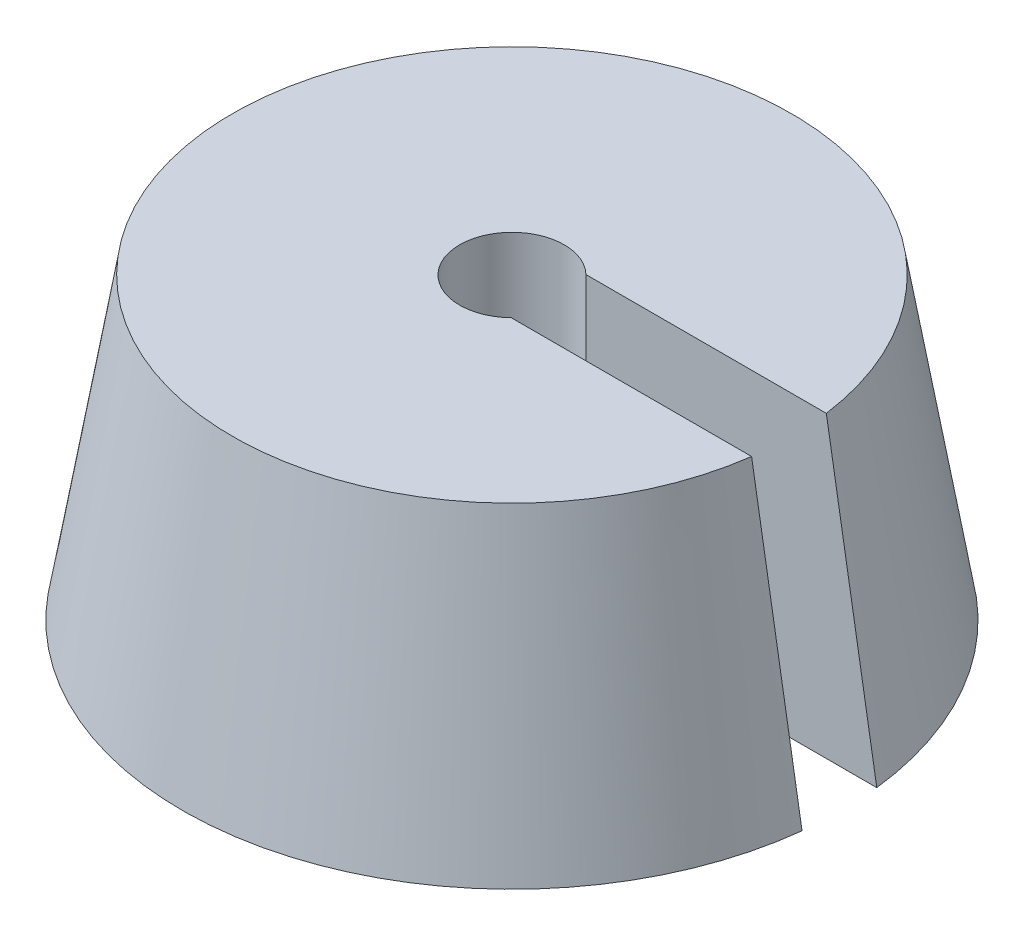
from build123d import *

# Parameters (mm, degrees)
SKETCH_1_R               = 22.05
SKETCH_2_R               = 18.7
CUT_EXTRUDE_2_DEPTH      = 1.0000001
CUT_EXTRUDE_2_DEPTH_BACK = 21.0000001


with BuildPart() as part:
    # 스케치1 → 로프트1 section 0
    with BuildSketch(Plane(origin=(0, 0, 0), x_dir=(1, 0, 0), z_dir=(0, 1, 0))):
        Circle(SKETCH_1_R)
    # 스케치2 → 로프트1 section 1
    with BuildSketch(Plane(origin=(0, 20, 0), x_dir=(1, 0, 0), z_dir=(0, 1, 0))):
        Circle(SKETCH_2_R)
    loft()

    # 스케치5 → 컷-돌출2 (cut, two sides)
    with BuildSketch(Plane(origin=(0, 20, 0), x_dir=(1, 0, 0), z_dir=(0, 1, 0))) as cut_extrude_2_sk:
        with BuildLine():
            Line((0, -2.5), (0, 2.5))
            Line((0, 2.5), (2.449489743, 2.5))
            ThreePointArc((2.449489743, 2.5), (-3.5, 0), (2.449489743, -2.5))
            Line((2.449489743, -2.5), (0, -2.5))
        make_face()
        with BuildLine():
            Line((2.449489743, 2.5), (0, 2.5))
            Line((0, 2.5), (0, -2.5))
            Line((0, -2.5), (2.449489743, -2.5))
            ThreePointArc((2.449489743, -2.5), (3.226702194, -1.355873501), (3.5, 0))
            ThreePointArc((3.5, 0), (3.226702194, 1.355873501), (2.449489743, 2.5))
        make_face()
        with BuildLine():
            Line((18.532134254, 2.5), (2.449489743, 2.5))
            ThreePointArc((2.449489743, 2.5), (3.226702194, 1.355873501), (3.5, 0))
            ThreePointArc((3.5, 0), (3.226702194, -1.355873501), (2.449489743, -2.5))
            Line((2.449489743, -2.5), (18.532134254, -2.5))
            ThreePointArc((18.532134254, -2.5), (18.657986367, -1.252814722), (18.7, 0))
            ThreePointArc((18.7, 0), (18.657986367, 1.252814722), (18.532134254, 2.5))
        make_face()
        with BuildLine():
            Line((26.590430579, 2.5), (18.532134254, 2.5))
            ThreePointArc((18.532134254, 2.5), (18.657986367, 1.252814722), (18.7, 0))
            ThreePointArc((18.7, 0), (18.657986367, -1.252814722), (18.532134254, -2.5))
            Line((18.532134254, -2.5), (26.590430579, -2.5))
            Line((26.590430579, -2.5), (26.590430579, 2.5))
        make_face()
    extrude(amount=CUT_EXTRUDE_2_DEPTH, mode=Mode.SUBTRACT)
    extrude(cut_extrude_2_sk.sketch, amount=-CUT_EXTRUDE_2_DEPTH_BACK, mode=Mode.SUBTRACT)


solid = part.part
